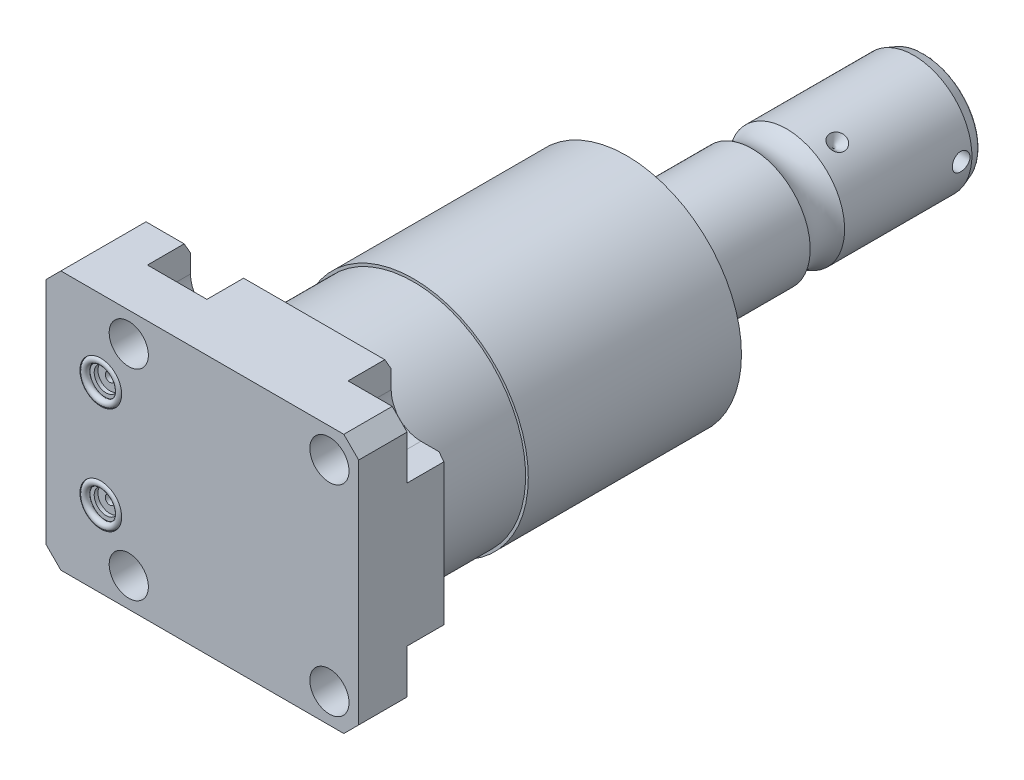
from build123d import *

# Parameters (mm, degrees)
SKETCH1_W            = 85.4964
SKETCH1_H            = 70.866
EXTRUDE1_DEPTH       = 25.019
SKETCH2_R            = 5.3594
CUT_EXTRUDE1_DEPTH   = 27.5209
LPATTERN1_COUNT      = 2
LPATTERN1_PITCH      = 54.864
LPATTERN1_COUNT_DIR2 = 2
LPATTERN1_PITCH_DIR2 = 54.864
CUT_EXTRUDE2_DEPTH   = 11.7856
SKETCH6_R            = 5.7023
CUT_EXTRUDE3_DEPTH   = 1.4478
SKETCH7_R            = 3.2512
CUT_EXTRUDE4_DEPTH   = 1.016
SKETCH8_R            = 1.2446
CUT_EXTRUDE5_DEPTH   = 11.9888
SKETCH9_R            = 0.9271
CHAMFER1_SIZE        = 4.064
CHAMFER2_SIZE        = 3.0226
CHAMFER2_SIZE2       = 1.745098924
SKETCH14_R           = 31.3944
EXTRUDE2_DEPTH       = 86.995
SKETCH15_OUTSIDE_W   = 119.1
SKETCH15_OUTSIDE_H   = 104.47
SKETCH15_OUTSIDE_R   = 30.6578
CUT_EXTRUDE9_DEPTH   = 25.4
SKETCH19_R           = 7.112
EXTRUDE3_DEPTH       = 1.524
SKETCH20_R           = 12.954
SKETCH20_R_2         = 12.573
CUT_EXTRUDE10_DEPTH  = 0.254
CUT_EXTRUDE11_DEPTH  = 8.001
CIRPATTERN1_COUNT    = 3
SKETCH23_W           = 3.81
SKETCH23_H           = 2.413
FILLET1_R            = 0.635


with BuildPart() as part:
    # Sketch1 → Extrude1 (new body)
    with BuildSketch(Plane.XY):
        with Locations((-7.3152, 0)):
            Rectangle(SKETCH1_W, SKETCH1_H)
    extrude(amount=EXTRUDE1_DEPTH)

    # Sketch2 → Cut-Extrude1 (cut)
    with BuildSketch(Plane(origin=(0, 0, 0), x_dir=(-1, 0, 0), z_dir=(0, 0, -1))):
        with Locations((-27.432, -27.432)):
            Circle(SKETCH2_R)
    cut_extrude1 = extrude(amount=-CUT_EXTRUDE1_DEPTH, mode=Mode.SUBTRACT)

    # LPattern1: Cut-Extrude1 2 × 2
    with Locations(*[(-j * LPATTERN1_PITCH_DIR2, i * LPATTERN1_PITCH, 0) for i in range(LPATTERN1_COUNT) for j in range(LPATTERN1_COUNT_DIR2) if (i, j) != (0, 0)]):
        add(cut_extrude1, mode=Mode.SUBTRACT)

    # Sketch3 → Cut-Extrude2 (cut)
    with BuildSketch(Plane(origin=(0, 0, 0), x_dir=(-1, 0, 0), z_dir=(0, 0, -1))):
        with BuildLine():
            Line((-27.432, -19.304), (-35.433, -19.304))
            Line((-35.433, -19.304), (-35.433, -35.433))
            Line((-35.433, -35.433), (-19.304, -35.433))
            Line((-19.304, -35.433), (-19.304, -27.432))
            ThreePointArc((-19.304, -27.432), (-21.684636083, -21.684636083), (-27.432, -19.304))
        make_face()
        with BuildLine():
            Line((-35.433, 19.304), (-35.433, 35.433))
            Line((-35.433, 35.433), (-19.304, 35.433))
            Line((-19.304, 35.433), (-19.304, 27.432))
            ThreePointArc((-19.304, 27.432), (-21.684636083, 21.684636083), (-27.432, 19.304))
            Line((-27.432, 19.304), (-35.433, 19.304))
        make_face()
        with BuildLine():
            Line((19.304, 35.433), (19.304, 27.432))
            ThreePointArc((19.304, 27.432), (27.432, 19.304), (35.56, 27.432))
            Line((35.56, 27.432), (35.56, 35.433))
            Line((35.56, 35.433), (19.304, 35.433))
        make_face()
        with BuildLine():
            Line((35.56, -35.433), (19.304, -35.433))
            Line((19.304, -35.433), (19.304, -27.432))
            ThreePointArc((19.304, -27.432), (27.432, -19.304), (35.56, -27.432))
            Line((35.56, -27.432), (35.56, -35.433))
        make_face()
    extrude(amount=-CUT_EXTRUDE2_DEPTH, mode=Mode.SUBTRACT)

    # S2D0007 → Cut-Revolve1 (revolve, cut)
    with BuildSketch(Plane(origin=(-55.5498, -13.0048, 12.5222), x_dir=(0, 1, 0), z_dir=(0, 0, 1)), mode=Mode.PRIVATE) as cut_revolve1_sk:
        Polygon((0, -5.4864), (10.4775, -5.4864), (10.4775, -5.7404), (6.1849, -5.7404), (5.642306865, -8.2931), (4.9784, -8.957006865), (4.9784, -19.7104), (0, -19.7104), align=None)
    cut_revolve1 = revolve(cut_revolve1_sk.sketch.rotate(Axis((-35.077219214, -13.0048, 12.5222), (-1, 0, 0)), 90), axis=Axis((-35.077219214, -13.0048, 12.5222), (-1, 0, 0)), mode=Mode.SUBTRACT)  # turned: the seam where the file's is

    # Mirror1: Cut-Revolve1 across plane
    add(cut_revolve1.mirror(Plane.ZX), mode=Mode.SUBTRACT)

    # Sketch6 → Cut-Extrude3 (cut)
    with BuildSketch(Plane.XY.offset(25.019)):
        with Locations((-35.0774, -14.5288)):
            Circle(SKETCH6_R)
        with Locations((-35.0774, 14.5288)):
            Circle(SKETCH6_R)
    extrude(amount=-CUT_EXTRUDE3_DEPTH, mode=Mode.SUBTRACT)

    # Sketch7 → Cut-Extrude4 (cut)
    with BuildSketch(Plane.XY.offset(23.5712)):
        with Locations((-35.0774, 14.5288)):
            Circle(SKETCH7_R)
        with Locations((-35.0774, -14.5288)):
            Circle(SKETCH7_R)
    extrude(amount=-CUT_EXTRUDE4_DEPTH, mode=Mode.SUBTRACT)

    # Sketch8 → Cut-Extrude5 (cut)
    with BuildSketch(Plane.XY.offset(22.5552)):
        with Locations((-35.0774, 14.5288)):
            Circle(SKETCH8_R)
        with Locations((-35.0774, -14.5288)):
            Circle(SKETCH8_R)
    extrude(amount=-CUT_EXTRUDE5_DEPTH, mode=Mode.SUBTRACT)

    # Chamfer1
    chamfer1_edges = [part.edges().sort_by_distance(p)[0] for p in [
        (-50.0634, 35.433, 12.5095),
        (35.433, 35.433, 18.4023),
        (35.433, -35.433, 18.4023),
        (-50.0634, -35.433, 12.5095),
    ]]
    chamfer(chamfer1_edges, length=CHAMFER1_SIZE)

    # Chamfer2
    chamfer2_edges = [part.edges().sort_by_distance(p)[0] for p in [
        (-40.7797, -35.433, 0),
        (35.433, 0, 0),
        (0, 35.433, 0),
        (-40.7797, 35.433, 0),
        (0, -35.433, 0),
    ]]
    chamfer2_side = [part.faces().sort_by_distance(p)[0] for p in [
        (-8.721448678, 0, 0),
    ]]
    chamfer(chamfer2_edges, length=CHAMFER2_SIZE, length2=CHAMFER2_SIZE2, reference=chamfer2_side[0])

    # Sketch14 → Extrude2 (add)
    with BuildSketch(Plane(origin=(0, 0, 0), x_dir=(-1, 0, 0), z_dir=(0, 0, -1))):
        with Locations(Location((0, 0, 0), (0, 0, 140.520960584))):  # turned: the seam where the file's is
            Circle(SKETCH14_R)
    extrude(amount=EXTRUDE2_DEPTH)

    # Sketch15 outside → Cut-Extrude9 (cut)
    with BuildSketch(Plane(origin=(0, 0, 0), x_dir=(-1, 0, 0), z_dir=(0, 0, -1))):
        with Locations((7.315, 0)):
            Rectangle(SKETCH15_OUTSIDE_W, SKETCH15_OUTSIDE_H)
        Circle(SKETCH15_OUTSIDE_R, mode=Mode.SUBTRACT)
    extrude(amount=CUT_EXTRUDE9_DEPTH, mode=Mode.SUBTRACT)

    # Sketch16 → Cut-Revolve3 (revolve, cut)
    with BuildSketch(Plane(origin=(0, 0, 0), x_dir=(0, 0, 1), z_dir=(1, 0, 0)), mode=Mode.PRIVATE) as cut_revolve3_sk:
        Polygon((-86.995, 19.05), (-83.687327989, 31.3944), (-86.995, 31.3944), align=None)
    revolve(cut_revolve3_sk.sketch.rotate(Axis((0, 0, -96.582204284), (0, 0, 1)), 270), axis=Axis((0, 0, -96.582204284), (0, 0, 1)), mode=Mode.SUBTRACT)  # turned: the seam where the file's is

    # Sketch17 → Revolve3 (revolve)
    with BuildSketch(Plane(origin=(0, 0, 0), x_dir=(0, 0, 1), z_dir=(1, 0, 0)), mode=Mode.PRIVATE) as revolve3_sk:
        with BuildLine():
            Line((-86.995, 0), (-86.995, 15.875))
            Line((-86.995, 15.875), (-118.00030643, 15.875))
            ThreePointArc((-118.00030643, 15.875), (-122.7074, 14.3256), (-127.41449357, 15.875))
            Line((-127.41449357, 15.875), (-162.2044, 15.875))
            Line((-162.2044, 15.875), (-165.1254, 14.811842946))
            Line((-165.1254, 14.811842946), (-165.1254, 0))
            Line((-165.1254, 0), (-86.995, 0))
        make_face()
    revolve(revolve3_sk.sketch.rotate(Axis((0, 0, -180.9369), (0, 0, 1)), 270), axis=Axis((0, 0, -180.9369), (0, 0, 1)))  # turned: the seam where the file's is

    # Sketch19 → Extrude3 (add)
    with BuildSketch(Plane.ZY.offset(49.8094)):
        with Locations(Location((12.5222, -13.0048, 0), (0, 0, 180))):  # turned: the seam where the file's is
            Circle(SKETCH19_R)
    extrude(amount=EXTRUDE3_DEPTH)

    # Sketch20 → Cut-Extrude10 (cut)
    with BuildSketch(Plane(origin=(0, 0, -165.1254), x_dir=(-1, 0, 0), z_dir=(0, 0, -1))):
        Circle(SKETCH20_R)
        Circle(SKETCH20_R_2, mode=Mode.SUBTRACT)
    extrude(amount=-CUT_EXTRUDE10_DEPTH, mode=Mode.SUBTRACT)

    # Sketch21 → Cut-Extrude11 (cut)
    with BuildSketch(Plane(origin=(0, 0, -165.1254), x_dir=(-1, 0, 0), z_dir=(0, 0, -1))):
        Polygon((4.619379504, 0), (2.309689752, 4.0005), (-2.309689752, 4.0005), (-4.619379504, 0), (-2.309689752, -4.0005), (2.309689752, -4.0005), align=None)
    extrude(amount=-CUT_EXTRUDE11_DEPTH, mode=Mode.SUBTRACT)

    # Sketch22 → Cut-Revolve4 (revolve, cut)
    with BuildSketch(Plane(origin=(0, 0, 0), x_dir=(1, 0, 0), z_dir=(0, 1, 0)), mode=Mode.PRIVATE) as cut_revolve4_sk:
        Polygon((-15.875, 135.7884), (-15.875, 133.3754), (-13.462, 133.3754), align=None)
    cut_revolve4 = revolve(cut_revolve4_sk.sketch.rotate(Axis((-21.668802649, 0, -133.3754), (1, 0, 0)), 180), axis=Axis((-21.668802649, 0, -133.3754), (1, 0, 0)), mode=Mode.SUBTRACT)  # turned: the seam where the file's is

    # CirPattern1: Cut-Revolve4 ×3 about axis
    cirpattern1_axis = Axis((0, 0, -180.9369), (0, 0, -1))
    for i in range(1, CIRPATTERN1_COUNT):
        add(cut_revolve4.rotate(cirpattern1_axis, i * 360 / CIRPATTERN1_COUNT), mode=Mode.SUBTRACT)

    # Sketch23 → Cut-Revolve5 (revolve, cut)
    with BuildSketch(Plane(origin=(0, 0, 0), x_dir=(1, 0, 0), z_dir=(0, 1, 0)), mode=Mode.PRIVATE) as cut_revolve5_sk:
        with Locations((13.97, 160.4899)):
            Rectangle(SKETCH23_W, SKETCH23_H)
    revolve(cut_revolve5_sk.sketch.rotate(Axis((-15.875, 0, -159.2834), (1, 0, 0)), 180), axis=Axis((-15.875, 0, -159.2834), (1, 0, 0)), mode=Mode.SUBTRACT)  # turned: the seam where the file's is

    # Fillet1
    fillet1_edges = [part.edges().sort_by_distance(p)[0] for p in [
        (14.811842946, 0, -165.1254),
    ]]
    fillet(fillet1_edges, radius=FILLET1_R)


with BuildPart() as body_2:
    # Sketch9 → Revolve1 (revolve)
    with BuildSketch(Plane(origin=(-41.656, -14.5288, 23.5712), x_dir=(1, 0, 0), z_dir=(0, 1, 0))):
        with Locations((11.3538, -0.9271)):
            Circle(SKETCH9_R)
    revolve(axis=Axis((-35.0774, -14.5288, 25.51811), (0, 0, -1)))


with BuildPart() as body_3:
    # Mirror2: mirrored copy
    add(body_2.part.mirror(Plane.ZX))


solid = Compound([part.part, body_2.part, body_3.part])
